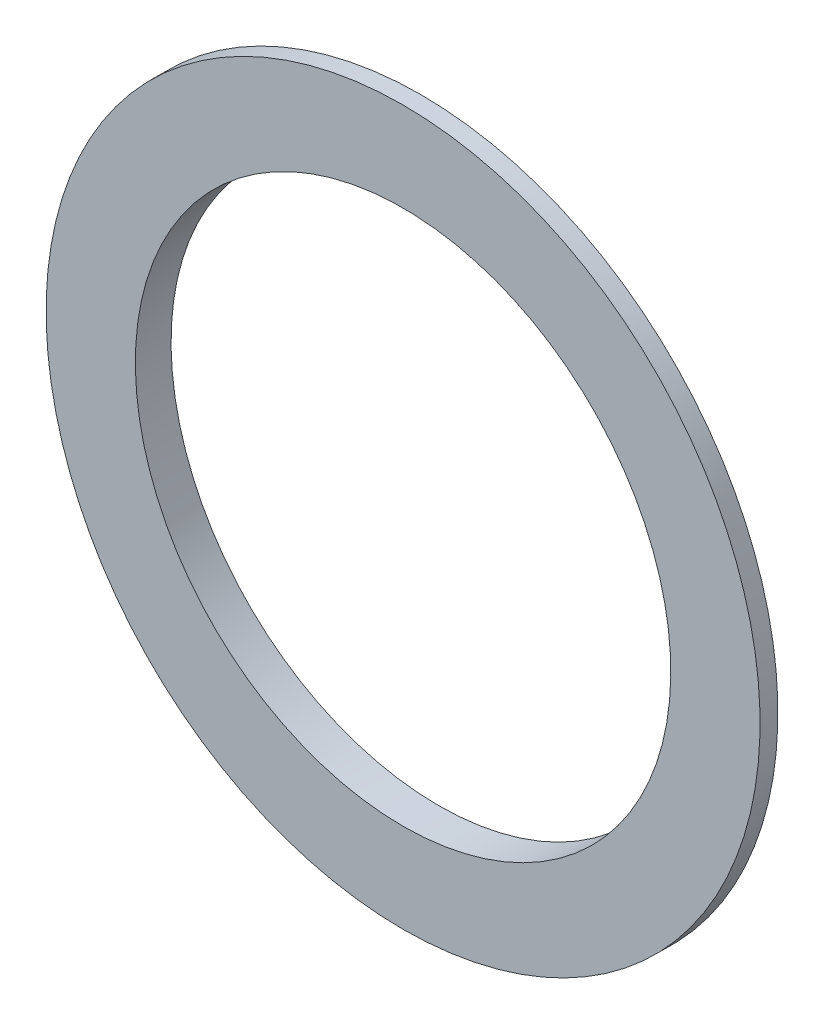
from build123d import *


with BuildPart() as part:
    # Sketch1 → Revolve1 (revolve)
    with BuildSketch(Plane(origin=(0, 0, 0), x_dir=(0, 0, -1), z_dir=(1, 0, 0))):
        Polygon((-3.175, 47.625), (3.175, 47.625), (3.175, 50.8), (0, 50.8), (0, 53.975), (3.175, 53.975), (3.175, 57.15), (0, 57.15), (0, 63.5), (-3.175, 63.5), align=None)
    revolve(axis=Axis((0, 0, 3.175), (0, 0, -1)))


solid = part.part
